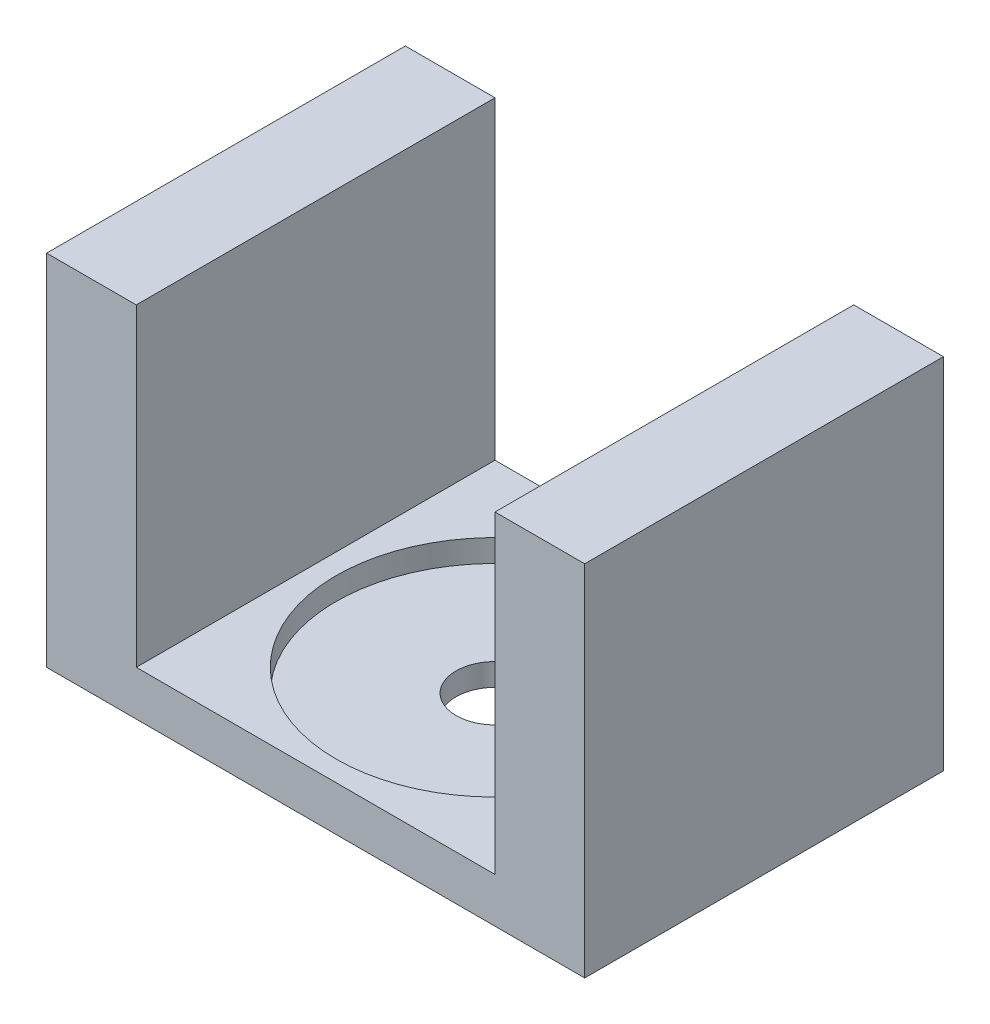
from build123d import *

# Parameters (mm, degrees)
BOSS_EXTRUDE1_DEPTH = 50.8
SKETCH2_R           = 22.5044
CUT_EXTRUDE1_DEPTH  = 3.175
SKETCH3_R           = 5.5
CUT_EXTRUDE2_DEPTH  = 4.175


with BuildPart() as part:
    # Sketch1 → Boss-Extrude1 (new body)
    with BuildSketch(Plane.XY):
        Polygon((38.1, 0), (-38.1, 0), (-38.1, 50.8), (-25.4, 50.8), (-25.4, 6.35), (25.4, 6.35), (25.4, 50.8), (38.1, 50.8), align=None)
    extrude(amount=BOSS_EXTRUDE1_DEPTH)

    # Sketch2 → Cut-Extrude1 (cut)
    with BuildSketch(Plane(origin=(0, 6.35, 0), x_dir=(1, 0, 0), z_dir=(0, 1, 0))):
        with Locations((0, -25.4)):
            Circle(SKETCH2_R)
    extrude(amount=-CUT_EXTRUDE1_DEPTH, mode=Mode.SUBTRACT)

    # Sketch3 → Cut-Extrude2 (cut, through all)
    with BuildSketch(Plane(origin=(0, 3.175, 0), x_dir=(1, 0, 0), z_dir=(0, 1, 0))):
        with Locations((0, -25.4)):
            Circle(SKETCH3_R)
    extrude(amount=-CUT_EXTRUDE2_DEPTH, mode=Mode.SUBTRACT)


solid = part.part
